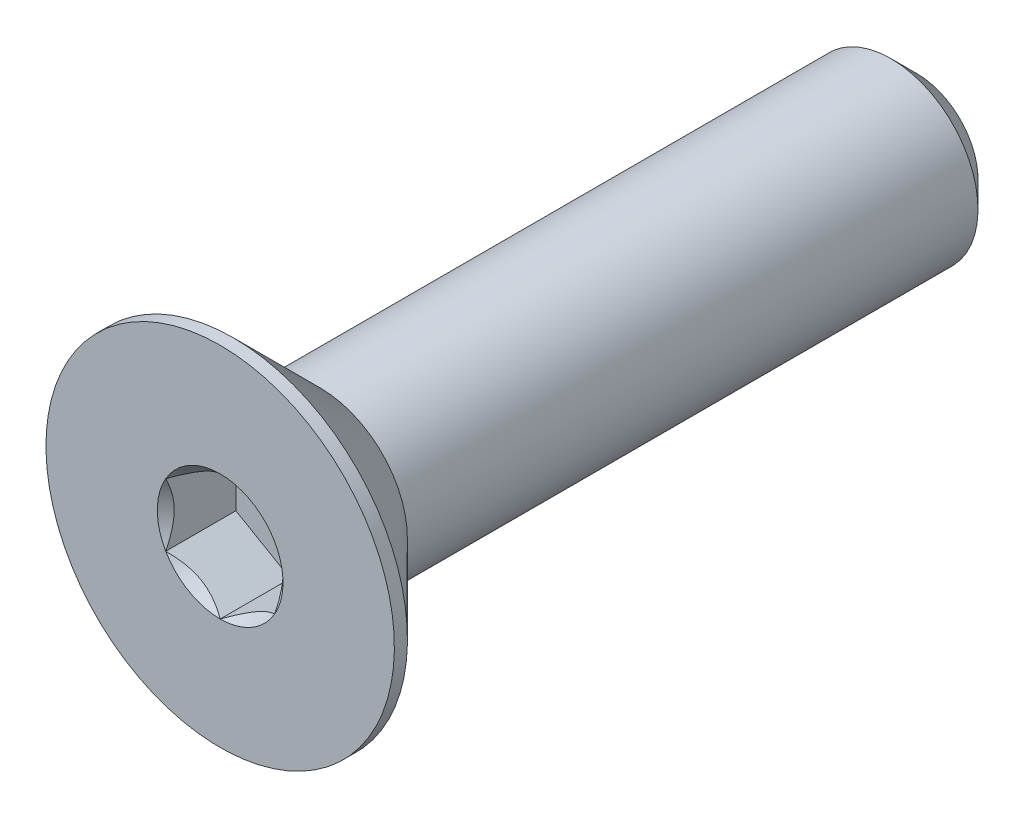
from build123d import *

# Parameters (mm, degrees)
SKETCH3_W          = 16
SKETCH3_H          = 2
CHAMFER1_SIZE      = 0.6
CUT_EXTRUDE1_DEPTH = 1.61
SKETCH9_R          = 1.443375673
CUT_EXTRUDE2_DEPTH = 1.61
CUT_EXTRUDE2_DRAFT = -45


with BuildPart() as part:
    # Sketch3 → Revolve1 (revolve)
    with BuildSketch(Plane(origin=(0, 0, 0), x_dir=(0, 0, -1), z_dir=(1, 0, 0))):
        with Locations((0, 1)):
            Rectangle(SKETCH3_W, SKETCH3_H)
    revolve(axis=Axis((0, 0, -8), (0, 0, 1)))

    # Chamfer1
    chamfer1_edges = [part.edges().sort_by_distance(p)[0] for p in [
        (0, -2, -8),
    ]]
    chamfer(chamfer1_edges, length=CHAMFER1_SIZE)

    # Sketch6 → Revolve2 (revolve)
    with BuildSketch(Plane(origin=(0, 0, 0), x_dir=(0, 0, -1), z_dir=(1, 0, 0))):
        Polygon((-8, 4), (-7.7, 4), (-5.7, 2), (-5.7, 0), (-8, 0), align=None)
    revolve(axis=Axis((0, 0, -8), (0, 0, 1)))

    # Sketch8 → Cut-Extrude1 (cut)
    with BuildSketch(Plane.XY.offset(8)):
        Polygon((0, 1.443375673), (-1.25, 0.721687836), (-1.25, -0.721687836), (0, -1.443375673), (1.25, -0.721687836), (1.25, 0.721687836), align=None)
    extrude(amount=-CUT_EXTRUDE1_DEPTH, mode=Mode.SUBTRACT)


with BuildPart() as cut_extrude2_tool:
    # Sketch9 → Cut-Extrude2 (with draft: the straight prism first)
    with BuildSketch(Plane.XY.offset(8)):
        Circle(SKETCH9_R)
    extrude(amount=-CUT_EXTRUDE2_DEPTH)
    # Cut-Extrude2: the draft: its side faces are tilted about the plane it starts from
    cut_extrude2_sides = [cut_extrude2_tool.faces().sort_by_distance(p)[0] for p in [
        (-1.443375673, 0, 7.195),
    ]]
    draft(cut_extrude2_sides, Plane.XY.offset(8), CUT_EXTRUDE2_DRAFT)


with BuildPart() as part_1:
    add(part.part)

    # Cut-Extrude2: cut by cut_extrude2_tool
    add(cut_extrude2_tool.part, mode=Mode.SUBTRACT)


solid = part_1.part
